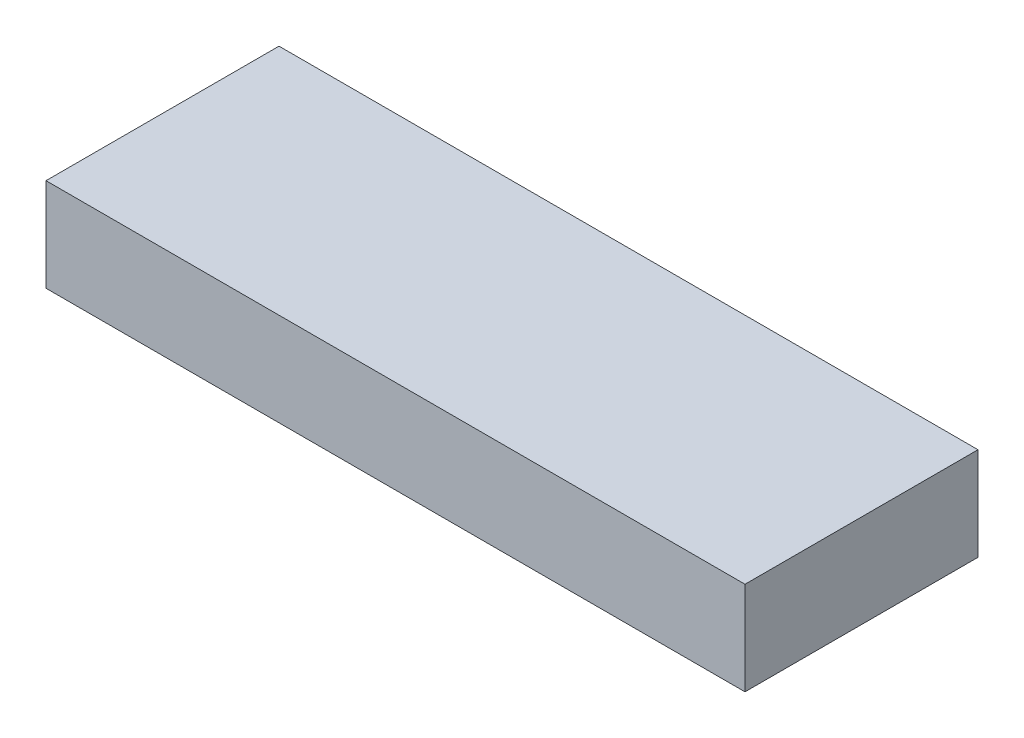
from build123d import *

# Parameters (mm, degrees)
SKIZZE8_W                       = 300
SKIZZE8_H                       = 100
AUFSATZ_LINEAR_AUSTRAGEN1_DEPTH = 20


with BuildPart() as part:
    # Skizze8 → Aufsatz-Linear austragen1 (new body, symmetric)
    with BuildSketch(Plane(origin=(0, 0, 0), x_dir=(1, 0, 0), z_dir=(0, 1, 0))):
        Rectangle(SKIZZE8_W, SKIZZE8_H)
    extrude(amount=AUFSATZ_LINEAR_AUSTRAGEN1_DEPTH, both=True)


solid = part.part
